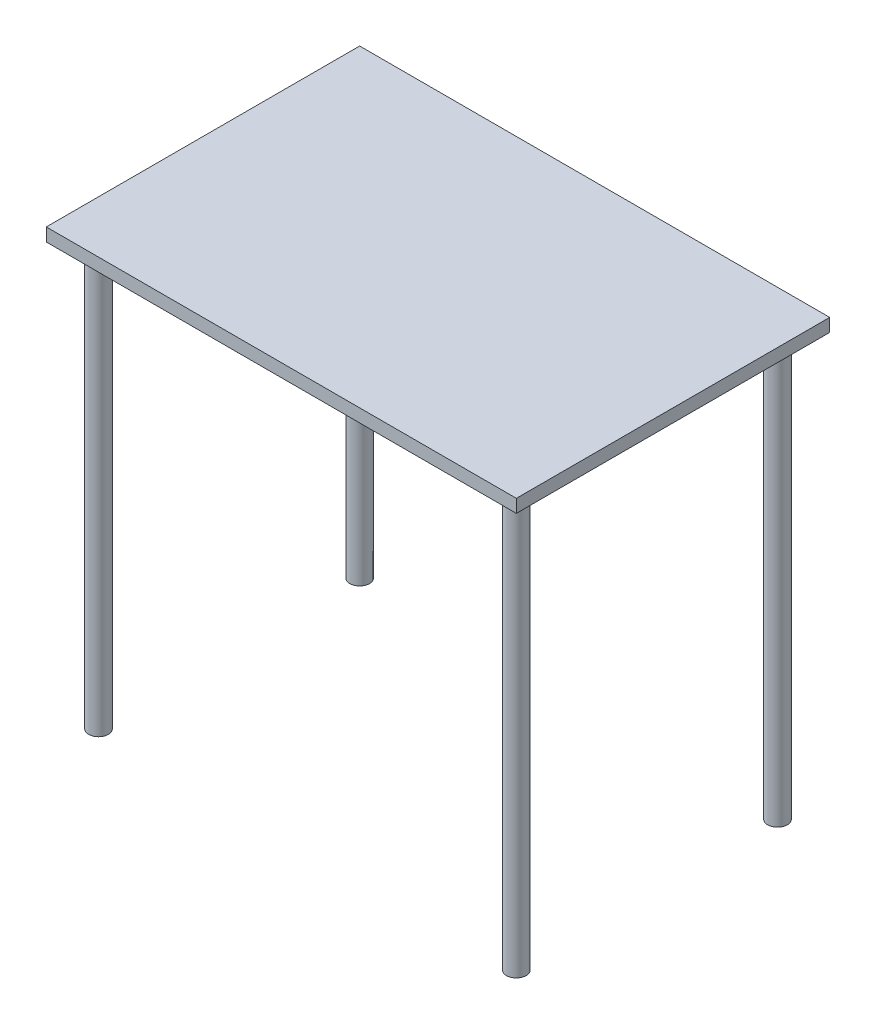
from build123d import *

# Parameters (mm, degrees)
SKETCH3_W   = 914.4
SKETCH3_H   = 609.6
TABLE_DEPTH = 25.4
SKETCH4_R   = 19.05
LEGS_DEPTH  = 820.0644


with BuildPart() as part:
    # Sketch3 → Table (new body)
    with BuildSketch(Plane(origin=(0, 0, 0), x_dir=(1, 0, 0), z_dir=(0, 1, 0))):
        with Locations((457.2, 304.8)):
            Rectangle(SKETCH3_W, SKETCH3_H)
    extrude(amount=TABLE_DEPTH)

    # Sketch4 → Legs (add)
    with BuildSketch(Plane.XZ):
        with Locations((50.8, -50.8)):
            Circle(SKETCH4_R)
        with Locations((863.6, -50.8)):
            Circle(SKETCH4_R)
        with Locations((50.8, -558.8)):
            Circle(SKETCH4_R)
        with Locations((863.6, -558.8)):
            Circle(SKETCH4_R)
    extrude(amount=LEGS_DEPTH)


solid = part.part
